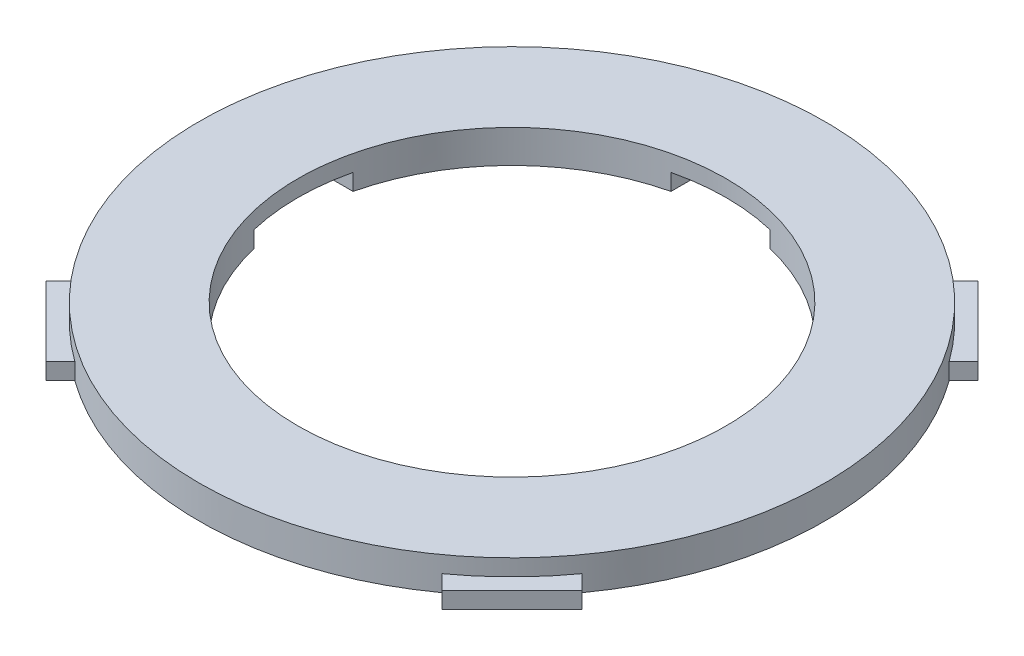
from build123d import *

# Parameters (mm, degrees)
BOSS_EXTRUDE1_DEPTH = 10
BOSS_EXTRUDE2_DEPTH = 5
BOSS_EXTRUDE3_START = 5
BOSS_EXTRUDE3_DEPTH = 5


with BuildPart() as part:
    # Sketch1 → Boss-Extrude1 (new body)
    with BuildSketch(Plane(origin=(0, 0, 0), x_dir=(1, 0, 0), z_dir=(0, 1, 0))):
        with BuildLine():
            ThreePointArc((76.939097525, 55.725894089), (67.175144213, 67.175144213), (55.725894089, 76.939097525))
            ThreePointArc((55.725894089, 76.939097525), (0, 95), (-55.725894089, 76.939097525))
            ThreePointArc((-55.725894089, 76.939097525), (-67.175144213, 67.175144213), (-76.939097525, 55.725894089))
            ThreePointArc((-76.939097525, 55.725894089), (-95, 0), (-76.939097525, -55.725894089))
            ThreePointArc((-76.939097525, -55.725894089), (-67.175144213, -67.175144213), (-55.725894089, -76.939097525))
            ThreePointArc((-55.725894089, -76.939097525), (0, -95), (55.725894089, -76.939097525))
            ThreePointArc((55.725894089, -76.939097525), (67.175144213, -67.175144213), (76.939097525, -55.725894089))
            ThreePointArc((76.939097525, -55.725894089), (90.372048402, -29.289808254), (95, 0))
            ThreePointArc((95, 0), (90.372048402, 29.289808254), (76.939097525, 55.725894089))
        make_face()
        with BuildLine():
            Line((-63.245553203, -15), (-70, -15))
            Line((-70, -15), (-70, 15))
            Line((-70, 15), (-63.245553203, 15))
            ThreePointArc((-63.245553203, 15), (-45.961940777, 45.961940777), (-15, 63.245553203))
            Line((-15, 63.245553203), (-15, 70))
            Line((-15, 70), (15, 70))
            Line((15, 70), (15, 63.245553203))
            ThreePointArc((15, 63.245553203), (45.961940777, 45.961940777), (63.245553203, 15))
            Line((63.245553203, 15), (70, 15))
            Line((70, 15), (70, -15))
            Line((70, -15), (63.245553203, -15))
            ThreePointArc((63.245553203, -15), (45.961940777, -45.961940777), (15, -63.245553203))
            Line((15, -63.245553203), (15, -70))
            Line((15, -70), (-15, -70))
            Line((-15, -70), (-15, -63.245553203))
            ThreePointArc((-15, -63.245553203), (-45.961940777, -45.961940777), (-63.245553203, -15))
        make_face(mode=Mode.SUBTRACT)
    extrude(amount=BOSS_EXTRUDE1_DEPTH)

    # Sketch1_3 → Boss-Extrude2 (add)
    with BuildSketch(Plane(origin=(0, 0, 0), x_dir=(1, 0, 0), z_dir=(0, 1, 0))):
        with BuildLine():
            Line((81.317279836, 60.104076401), (60.104076401, 81.317279836))
            Line((60.104076401, 81.317279836), (55.725894089, 76.939097525))
            ThreePointArc((55.725894089, 76.939097525), (67.175144213, 67.175144213), (76.939097525, 55.725894089))
            Line((76.939097525, 55.725894089), (81.317279836, 60.104076401))
        make_face()
        with BuildLine():
            ThreePointArc((-76.939097525, 55.725894089), (-67.175144213, 67.175144213), (-55.725894089, 76.939097525))
            Line((-55.725894089, 76.939097525), (-60.104076401, 81.317279836))
            Line((-60.104076401, 81.317279836), (-81.317279836, 60.104076401))
            Line((-81.317279836, 60.104076401), (-76.939097525, 55.725894089))
        make_face()
        with BuildLine():
            Line((81.317279836, -60.104076401), (76.939097525, -55.725894089))
            ThreePointArc((76.939097525, -55.725894089), (67.175144213, -67.175144213), (55.725894089, -76.939097525))
            Line((55.725894089, -76.939097525), (60.104076401, -81.317279836))
            Line((60.104076401, -81.317279836), (81.317279836, -60.104076401))
        make_face()
        with BuildLine():
            ThreePointArc((-55.725894089, -76.939097525), (-67.175144213, -67.175144213), (-76.939097525, -55.725894089))
            Line((-76.939097525, -55.725894089), (-81.317279836, -60.104076401))
            Line((-81.317279836, -60.104076401), (-60.104076401, -81.317279836))
            Line((-60.104076401, -81.317279836), (-55.725894089, -76.939097525))
        make_face()
    extrude(amount=BOSS_EXTRUDE2_DEPTH)

    # Sketch1_4 → Boss-Extrude3 (add)
    with BuildSketch(Plane(origin=(0, 0, 0), x_dir=(1, 0, 0), z_dir=(0, 1, 0)).offset(BOSS_EXTRUDE3_START)):
        with BuildLine():
            Line((-70, 15), (-70, -15))
            Line((-70, -15), (-63.245553203, -15))
            ThreePointArc((-63.245553203, -15), (-65, 0), (-63.245553203, 15))
            Line((-63.245553203, 15), (-70, 15))
        make_face()
        with BuildLine():
            ThreePointArc((15, -63.245553203), (0, -65), (-15, -63.245553203))
            Line((-15, -63.245553203), (-15, -70))
            Line((-15, -70), (15, -70))
            Line((15, -70), (15, -63.245553203))
        make_face()
        with BuildLine():
            Line((-15, 70), (-15, 63.245553203))
            ThreePointArc((-15, 63.245553203), (0, 65), (15, 63.245553203))
            Line((15, 63.245553203), (15, 70))
            Line((15, 70), (-15, 70))
        make_face()
        with BuildLine():
            ThreePointArc((63.245553203, 15), (65, 0), (63.245553203, -15))
            Line((63.245553203, -15), (70, -15))
            Line((70, -15), (70, 15))
            Line((70, 15), (63.245553203, 15))
        make_face()
    extrude(amount=BOSS_EXTRUDE3_DEPTH)


solid = part.part
